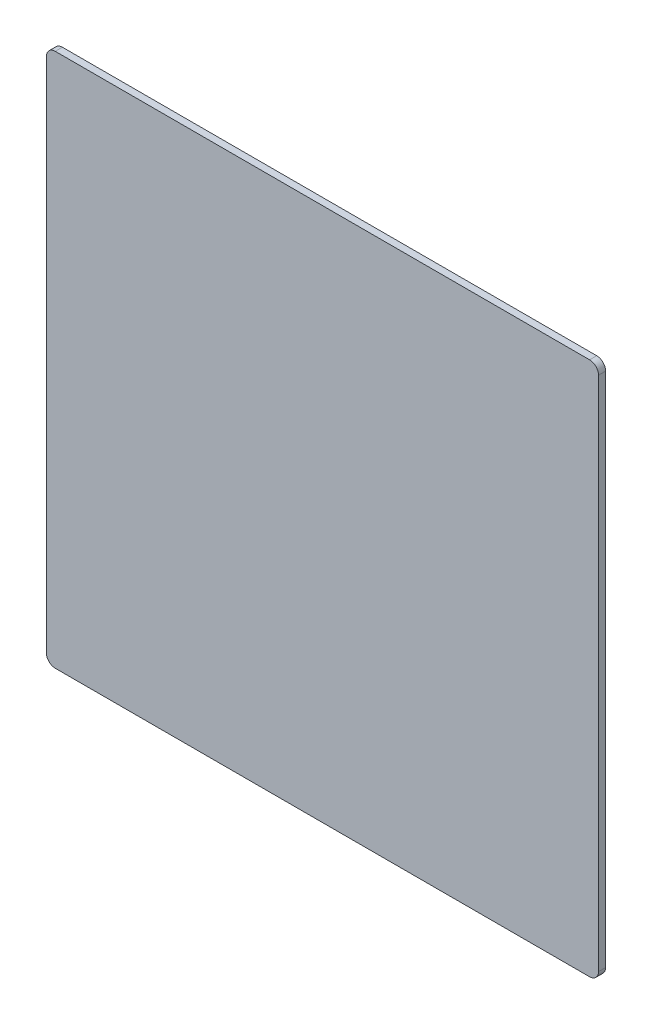
from build123d import *

# Parameters (mm, degrees)
SKETCH_1_W      = 310
SKETCH_1_H      = 300
EXTRUDE_1_DEPTH = 4
FILLET_1_R      = 5


with BuildPart() as part:
    # ｽｹｯﾁ1 → ﾎﾞｽ - 押し出し1 (new body)
    with BuildSketch(Plane.XY):
        Rectangle(SKETCH_1_W, SKETCH_1_H)
    extrude(amount=EXTRUDE_1_DEPTH)

    # ﾌｨﾚｯﾄ1
    fillet_1_edges = [part.edges().sort_by_distance(p)[0] for p in [
        (155, -150, 2),
        (-155, -150, 2),
        (-155, 150, 2),
        (155, 150, 2),
    ]]
    fillet(fillet_1_edges, radius=FILLET_1_R)


solid = part.part
